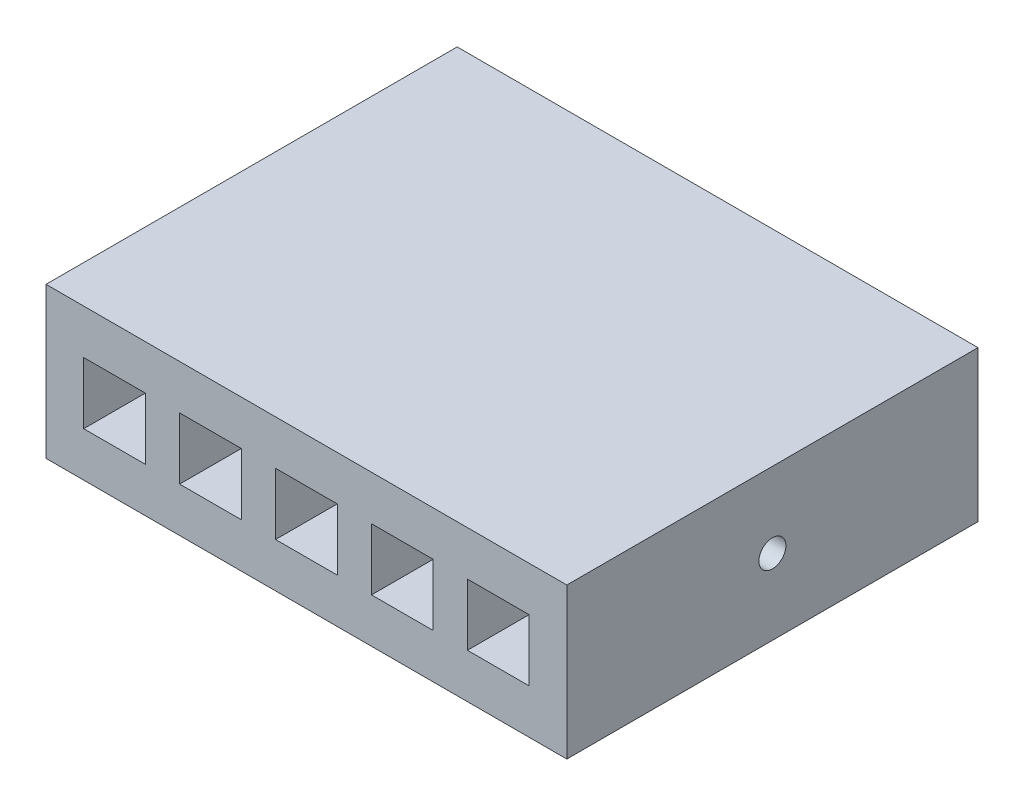
from build123d import *

# Parameters (mm, degrees)
SKETCH1_W           = 96.52
SKETCH1_H           = 76.2
BOSS_EXTRUDE1_DEPTH = 27.94
SKETCH2_W           = 11.43
SKETCH2_H           = 11.43
CUT_EXTRUDE1_DEPTH  = 11.43
SKETCH3_R           = 2.5
CUT_EXTRUDE2_DEPTH  = 12.7


with BuildPart() as part:
    # Sketch1 → Boss-Extrude1 (new body)
    with BuildSketch(Plane(origin=(0, 0, 0), x_dir=(1, 0, 0), z_dir=(0, 1, 0))):
        with Locations((48.26, 38.1)):
            Rectangle(SKETCH1_W, SKETCH1_H)
    extrude(amount=BOSS_EXTRUDE1_DEPTH)

    # Sketch2 → Cut-Extrude1 (cut)
    with BuildSketch(Plane.XY):
        with Locations((12.7, 13.97)):
            Rectangle(SKETCH2_W, SKETCH2_H)
        with Locations((30.48, 13.97)):
            Rectangle(SKETCH2_W, SKETCH2_H)
        with Locations((48.26, 13.97)):
            Rectangle(SKETCH2_W, SKETCH2_H)
        with Locations((66.04, 13.97)):
            Rectangle(SKETCH2_W, SKETCH2_H)
        with Locations((83.82, 13.97)):
            Rectangle(SKETCH2_W, SKETCH2_H)
    extrude(amount=-CUT_EXTRUDE1_DEPTH, mode=Mode.SUBTRACT)

    # Sketch3 → Cut-Extrude2 (cut)
    with BuildSketch(Plane(origin=(96.52, 0, 0), x_dir=(0, 0, -1), z_dir=(1, 0, 0))):
        with Locations((38.1, 13.97)):
            Circle(SKETCH3_R)
    extrude(amount=-CUT_EXTRUDE2_DEPTH, mode=Mode.SUBTRACT)


solid = part.part
